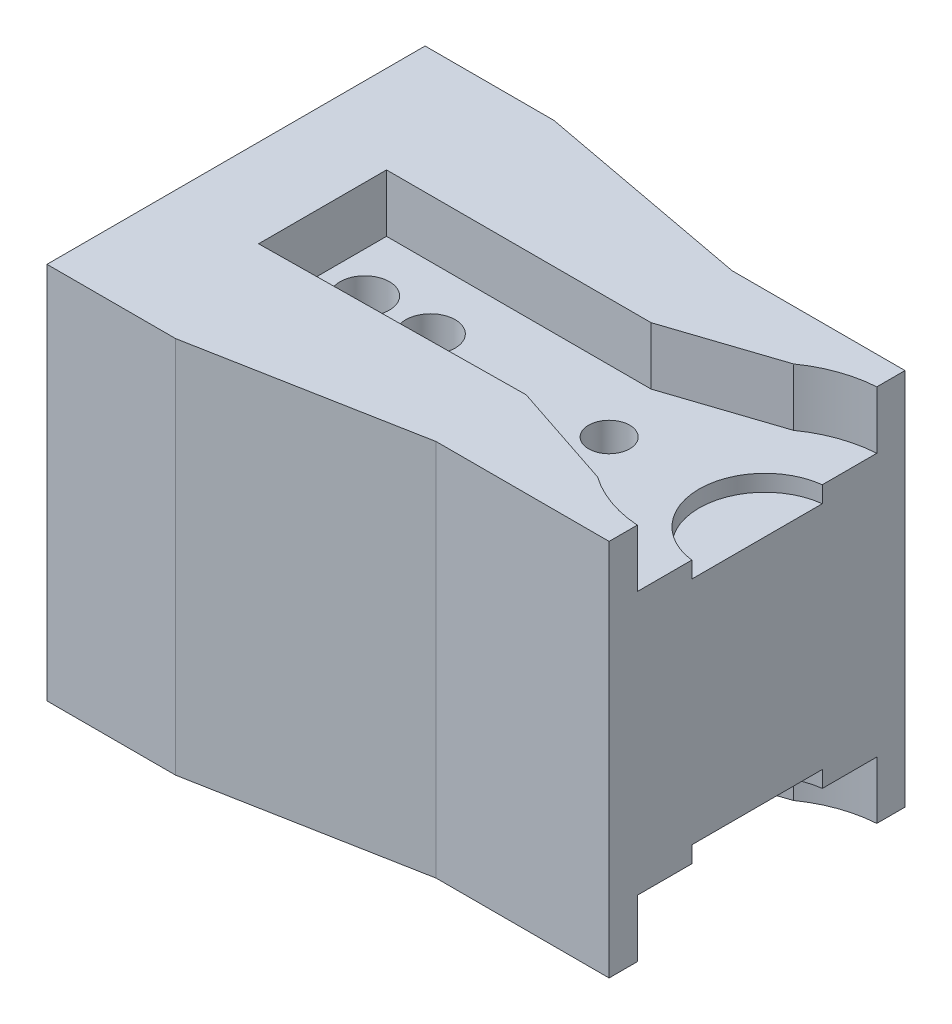
from build123d import *

# Parameters (mm, degrees)
BOSS_EXTRUDE1_DEPTH = 11.5
SKETCH1_13_R        = 1.5
SKETCH1_13_R_2      = 1.25
BOSS_EXTRUDE2_DEPTH = 8
BOSS_EXTRUDE3_DEPTH = 7


with BuildPart() as part:
    # Sketch1 → Boss-Extrude1 (new, symmetric)
    with BuildSketch(Plane(origin=(0, 0, 0), x_dir=(1, 0, 0), z_dir=(0, 1, 0))):
        with BuildLine():
            Line((6.824314586, 7.284360201), (6.824314586, 9.00020274))
            Line((6.824314586, 9.00020274), (-3.690467309, 9.00020274))
            Line((-3.690467309, 9.00020274), (-17.038497557, 11.5))
            Line((-17.038497557, 11.5), (-24.867971487, 11.5))
            Line((-24.867971487, 11.5), (-24.867971487, -11.5))
            Line((-24.867971487, -11.5), (-17.038497557, -11.5))
            Line((-17.038497557, -11.5), (-3.690467309, -9.00020274))
            Line((-3.690467309, -9.00020274), (6.824314586, -9.00020274))
            Line((6.824314586, -9.00020274), (6.824314586, -7.284360201))
            ThreePointArc((6.824314586, -7.284360201), (4.861171432, -6.879883717), (3.082035449, -5.956732906))
            Line((3.082035449, -5.956732906), (-3.422402494, -3.8))
            Line((-3.422402494, -3.8), (-19.513448301, -3.98254267))
            Line((-19.513448301, -3.98254267), (-19.513448301, 3.8))
            Line((-19.513448301, 3.8), (-3.422402494, 3.8))
            Line((-3.422402494, 3.8), (3.082035449, 5.956732906))
            ThreePointArc((3.082035449, 5.956732906), (4.861171432, 6.879883717), (6.824314586, 7.284360201))
        make_face()
    extrude(amount=BOSS_EXTRUDE1_DEPTH, both=True)

    # Sketch1_13 → Boss-Extrude2 (add, symmetric)
    with BuildSketch(Plane(origin=(0, 0, 0), x_dir=(1, 0, 0), z_dir=(0, 1, 0))):
        with BuildLine():
            Line((6.824314586, 3.971385595), (6.824314586, 7.284360201))
            ThreePointArc((6.824314586, 7.284360201), (4.861171432, 6.879883717), (3.082035449, 5.956732906))
            Line((3.082035449, 5.956732906), (-3.422402494, 3.8))
            Line((-3.422402494, 3.8), (-19.513448301, 3.8))
            Line((-19.513448301, 3.8), (-19.513448301, -3.98254267))
            Line((-19.513448301, -3.98254267), (-3.422402494, -3.8))
            Line((-3.422402494, -3.8), (3.082035449, -5.956732906))
            ThreePointArc((3.082035449, -5.956732906), (4.861171432, -6.879883717), (6.824314586, -7.284360201))
            Line((6.824314586, -7.284360201), (6.824314586, -3.971385595))
            ThreePointArc((6.824314586, -3.971385595), (3.301909035, 0), (6.824314586, 3.971385595))
        make_face()
        with Locations((-17.038497557, 0)):
            Circle(SKETCH1_13_R, mode=Mode.SUBTRACT)
        with Locations((-13.038497557, 0)):
            Circle(SKETCH1_13_R, mode=Mode.SUBTRACT)
        with Locations((-2.172402494, 0)):
            Circle(SKETCH1_13_R_2, mode=Mode.SUBTRACT)
    extrude(amount=BOSS_EXTRUDE2_DEPTH, both=True)

    # Sketch1_14 → Boss-Extrude3 (add, symmetric)
    with BuildSketch(Plane(origin=(0, 0, 0), x_dir=(1, 0, 0), z_dir=(0, 1, 0))):
        with BuildLine():
            Line((6.824314586, -3.971385595), (6.824314586, 3.971385595))
            ThreePointArc((6.824314586, 3.971385595), (3.301909035, 0), (6.824314586, -3.971385595))
        make_face()
    extrude(amount=BOSS_EXTRUDE3_DEPTH, both=True)


solid = part.part
